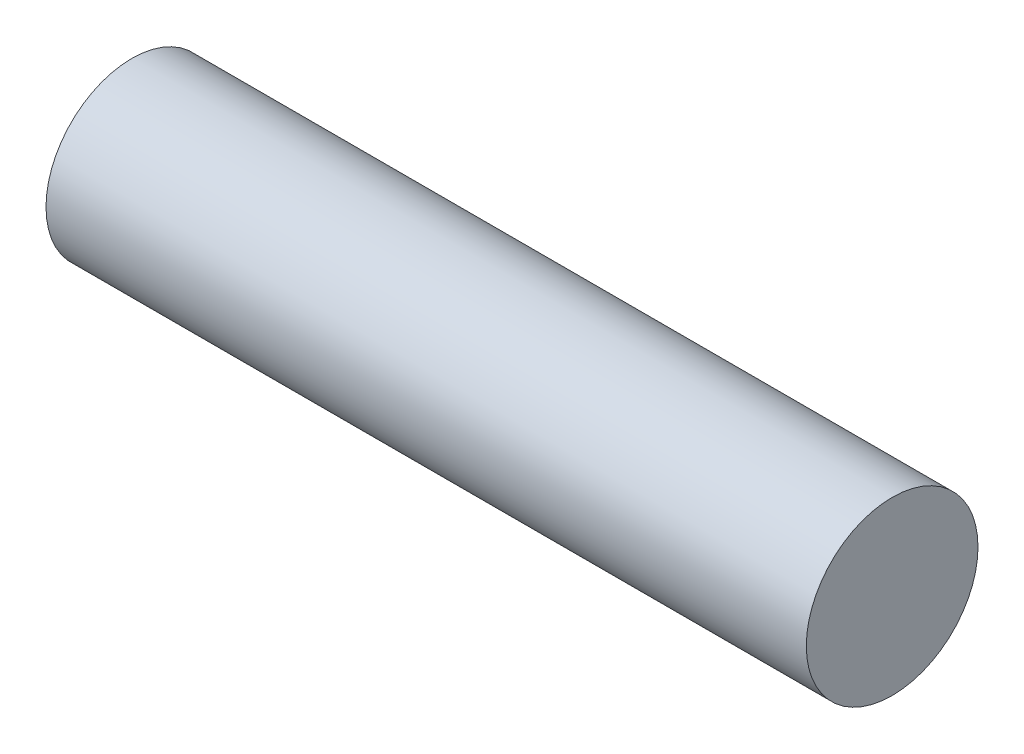
from build123d import *

# Parameters (mm, degrees)
SKETCH1_R           = 1.778
BOSS_EXTRUDE1_DEPTH = 7.874


with BuildPart() as part:
    # Sketch1 → Boss-Extrude1 (new body, symmetric)
    with BuildSketch(Plane(origin=(0, 0, 0), x_dir=(0, 0, -1), z_dir=(1, 0, 0))):
        Circle(SKETCH1_R)
    extrude(amount=BOSS_EXTRUDE1_DEPTH, both=True)


solid = part.part
